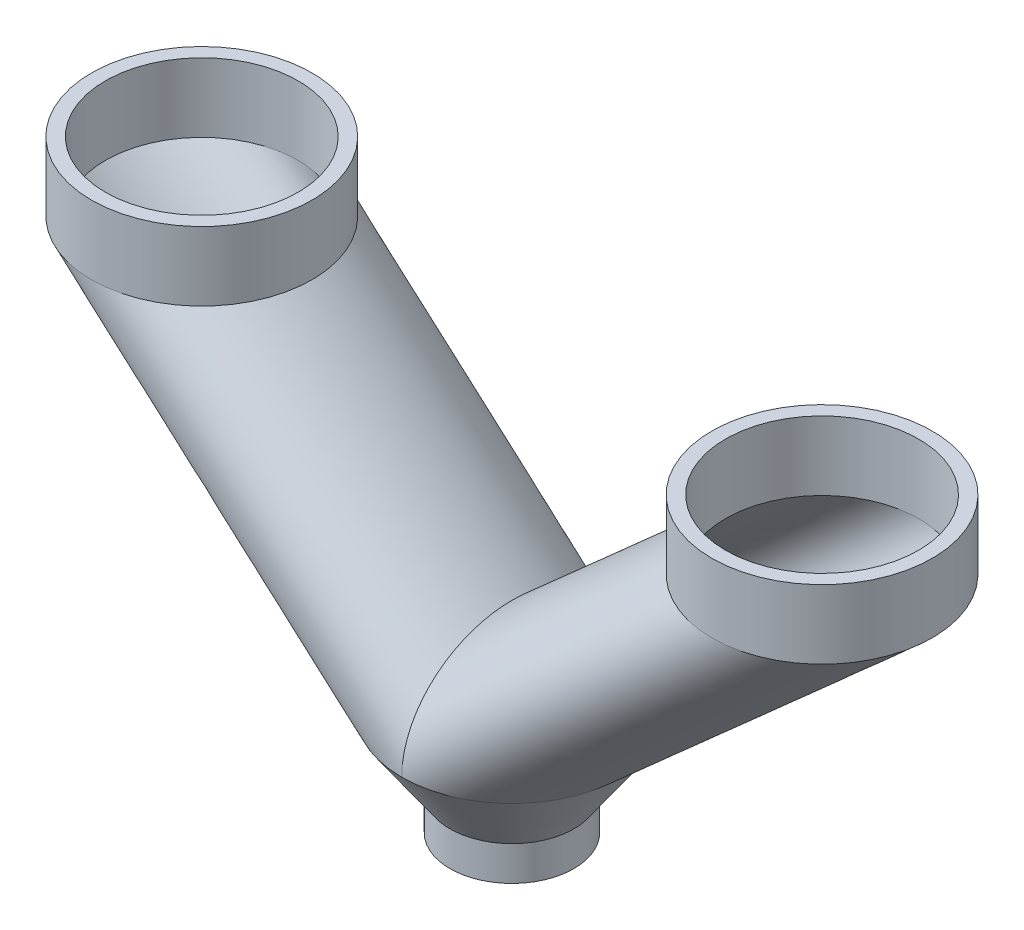
from build123d import *

# Parameters (mm, degrees)
CROQUIS18_R               = 16
CROQUIS18_R_2             = 14
SALIENTE_EXTRUIR3_DEPTH   = 10
SALIENTE_EXTRUIR3_2_DEPTH = 10
CROQUIS21_R               = 16
CROQUIS21_R_2             = 14
CROQUIS23_R               = 16
CROQUIS23_R_2             = 14
CROQUIS25_R               = 14
CROQUIS25_2_R             = 14
CROQUIS31_R               = 8.998021613
CROQUIS31_R_2             = 6.998021613
SALIENTE_EXTRUIR4_DEPTH   = 5


with BuildPart() as part:
    # Croquis18 → Saliente-Extruir3 (new body)
    with BuildSketch(Plane(origin=(0, 0, 0), x_dir=(1, 0, 0), z_dir=(0, 1, 0))):
        Circle(CROQUIS18_R)
        Circle(CROQUIS18_R_2, mode=Mode.SUBTRACT)
    extrude(amount=SALIENTE_EXTRUIR3_DEPTH)



with BuildPart() as body_2:
    # Croquis18 → Saliente-Extruir3 2 (new body)
    with BuildSketch(Plane(origin=(0, 0, 0), x_dir=(1, 0, 0), z_dir=(0, 1, 0))):
        with Locations((-90, 0)):
            Circle(CROQUIS18_R)
        with Locations((-90, 0)):
            Circle(CROQUIS18_R_2, mode=Mode.SUBTRACT)
    extrude(amount=SALIENTE_EXTRUIR3_2_DEPTH)

    # Barrer1: sweep along a path in Croquis19
    with BuildLine(Plane.XY) as barrer1_path:
        Line((-90, 0), (-45, -40))
    # Croquis21 → Barrer1 (sweep)
    with BuildSketch(Plane(origin=(0, -40, 0), x_dir=(1, 0, 0), z_dir=(0, 1, 0))):
        with Locations((-45, 0)):
            Circle(CROQUIS21_R)
        with Locations((-45, 0)):
            Circle(CROQUIS21_R_2, mode=Mode.SUBTRACT)
    sweep(path=barrer1_path.line)


with BuildPart() as part_1:
    add(part.part)

    add(body_2.part)  # Barrer2 merges body 2
    # Barrer2: sweep along a path in Croquis20
    with BuildLine(Plane.XY) as barrer2_path:
        Line((0, 0), (-45, -40))
    # Croquis23 → Barrer2 (sweep)
    with BuildSketch(Plane(origin=(0, -40, 0), x_dir=(1, 0, 0), z_dir=(0, 1, 0))):
        with Locations((-45, 0)):
            Circle(CROQUIS23_R)
        with Locations((-45, 0)):
            Circle(CROQUIS23_R_2, mode=Mode.SUBTRACT)
    sweep(path=barrer2_path.line)

    # Cortar-Barrer1: sweep along a path in Croquis20_2
    with BuildLine(Plane.XY) as cortar_barrer1_path:
        Line((0, 0), (-45, -40))
    # Croquis25 → Cortar-Barrer1 (sweep, cut)
    with BuildSketch(Plane.XZ.offset(40)):
        with Locations((-45, 0)):
            Circle(CROQUIS25_R)
    sweep(path=cortar_barrer1_path.line, mode=Mode.SUBTRACT)

    # Cortar-Barrer2: sweep along a path in Croquis19_2
    with BuildLine(Plane.XY) as cortar_barrer2_path:
        Line((-90, 0), (-45, -40))
    # Croquis25_2 → Cortar-Barrer2 (sweep, cut)
    with BuildSketch(Plane.XZ.offset(40)):
        with Locations((-45, 0)):
            Circle(CROQUIS25_2_R)
    sweep(path=cortar_barrer2_path.line, mode=Mode.SUBTRACT)

    # Croquis29 → Revolución2 (revolve)
    with BuildSketch(Plane.XY):
        Polygon((-61, -40), (-59, -40), (-52, -50), (-54, -50), align=None)
    revolve(axis=Axis((-45, -40, 0), (0, -1, 0)))

    # Croquis31 → Saliente-Extruir4 (add)
    with BuildSketch(Plane.XZ.offset(50)):
        with Locations((-45, -0.001978387)):
            Circle(CROQUIS31_R)
        with Locations((-45, -0.001978387)):
            Circle(CROQUIS31_R_2, mode=Mode.SUBTRACT)
    extrude(amount=SALIENTE_EXTRUIR4_DEPTH)


solid = part_1.part
